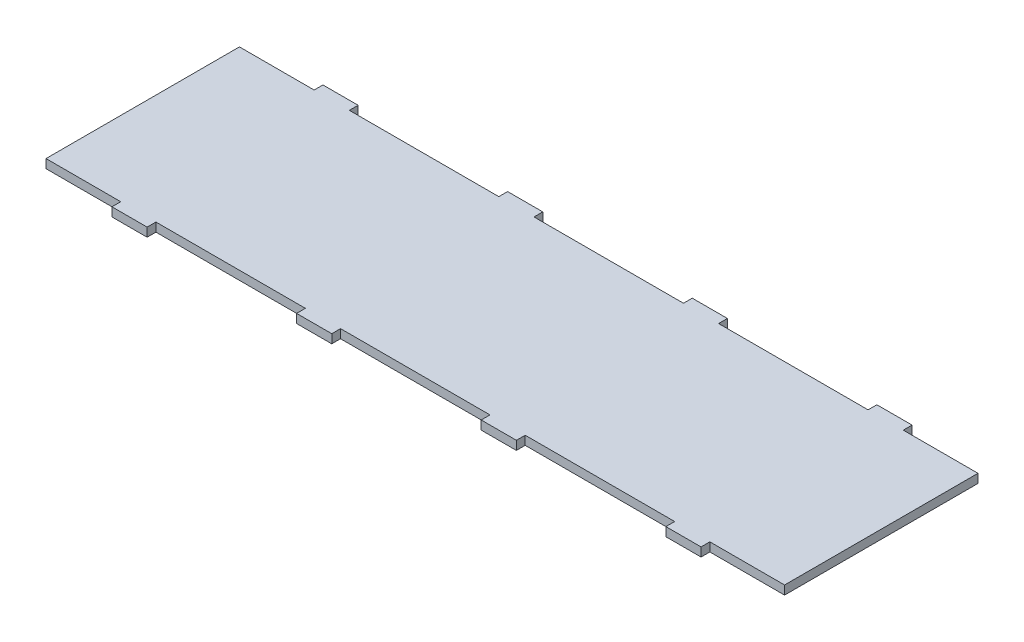
from build123d import *

# Parameters (mm, degrees)
SKETCH1_W               = 533.4
SKETCH1_H               = 152.4
BOSS_EXTRUDE1_DEPTH     = 6.35
SKETCH2_W               = 107.95
SKETCH2_H               = 6.35
CUT_EXTRUDE2_DEPTH      = 7.35
LPATTERN1_COUNT         = 3
LPATTERN1_PITCH         = 133.35
LPATTERN1_COL_COUNT     = 3
LPATTERN1_COL_PITCH     = 133.35
MIRROR2_COPY_1_SKETCH_W = 107.95
MIRROR2_COPY_1_SKETCH_H = 6.35
MIRROR2_COPY_1_DEPTH    = 7.35
MIRROR2_COPY_2_SKETCH_W = 107.95
MIRROR2_COPY_2_SKETCH_H = 6.35
MIRROR2_COPY_2_DEPTH    = 7.35
MIRROR2_COPY_3_SKETCH_W = 107.95
MIRROR2_COPY_3_SKETCH_H = 6.35
MIRROR2_COPY_3_DEPTH    = 7.35
MIRROR2_COPY_4_SKETCH_W = 107.95
MIRROR2_COPY_4_SKETCH_H = 6.35
MIRROR2_COPY_4_DEPTH    = 7.35


with BuildPart() as part:
    # Sketch1 → Boss-Extrude1 (new body)
    with BuildSketch(Plane(origin=(0, 0, 0), x_dir=(1, 0, 0), z_dir=(0, 1, 0))):
        Rectangle(SKETCH1_W, SKETCH1_H)
    extrude(amount=BOSS_EXTRUDE1_DEPTH)

    # Sketch2 → Cut-Extrude2 (cut, through all)
    with BuildSketch(Plane(origin=(0, 6.35, 0), x_dir=(1, 0, 0), z_dir=(0, 1, 0))):
        with Locations((0, -73.025)):
            Rectangle(SKETCH2_W, SKETCH2_H)
    cut_extrude2 = extrude(amount=-CUT_EXTRUDE2_DEPTH, mode=Mode.SUBTRACT)

    # LPattern1: Cut-Extrude2 ×3
    with Locations(*[(-i * LPATTERN1_PITCH, 0, 0) for i in range(1, LPATTERN1_COUNT)]):
        add(cut_extrude2, mode=Mode.SUBTRACT)

    # LPattern1 col: Cut-Extrude2 ×3
    with Locations(*[(i * LPATTERN1_COL_PITCH, 0, 0) for i in range(1, LPATTERN1_COL_COUNT)]):
        add(cut_extrude2, mode=Mode.SUBTRACT)

    # Mirror2: Cut-Extrude2 across plane
    add(cut_extrude2.mirror(Plane.XY), mode=Mode.SUBTRACT)

    # Mirror2 copy 1 sketch → Mirror2 copy 1 (cut, through all)
    with BuildSketch(Plane(origin=(-133.35, 6.35, 0), x_dir=(1, 0, 0), z_dir=(0, 1, 0))):
        with Locations((0, 73.025)):
            Rectangle(MIRROR2_COPY_1_SKETCH_W, MIRROR2_COPY_1_SKETCH_H)
    extrude(amount=-MIRROR2_COPY_1_DEPTH, mode=Mode.SUBTRACT)

    # Mirror2 copy 2 sketch → Mirror2 copy 2 (cut, through all)
    with BuildSketch(Plane(origin=(-266.7, 6.35, 0), x_dir=(1, 0, 0), z_dir=(0, 1, 0))):
        with Locations((0, 73.025)):
            Rectangle(MIRROR2_COPY_2_SKETCH_W, MIRROR2_COPY_2_SKETCH_H)
    extrude(amount=-MIRROR2_COPY_2_DEPTH, mode=Mode.SUBTRACT)

    # Mirror2 copy 3 sketch → Mirror2 copy 3 (cut, through all)
    with BuildSketch(Plane(origin=(133.35, 6.35, 0), x_dir=(1, 0, 0), z_dir=(0, 1, 0))):
        with Locations((0, 73.025)):
            Rectangle(MIRROR2_COPY_3_SKETCH_W, MIRROR2_COPY_3_SKETCH_H)
    extrude(amount=-MIRROR2_COPY_3_DEPTH, mode=Mode.SUBTRACT)

    # Mirror2 copy 4 sketch → Mirror2 copy 4 (cut, through all)
    with BuildSketch(Plane(origin=(266.7, 6.35, 0), x_dir=(1, 0, 0), z_dir=(0, 1, 0))):
        with Locations((0, 73.025)):
            Rectangle(MIRROR2_COPY_4_SKETCH_W, MIRROR2_COPY_4_SKETCH_H)
    extrude(amount=-MIRROR2_COPY_4_DEPTH, mode=Mode.SUBTRACT)


solid = part.part
